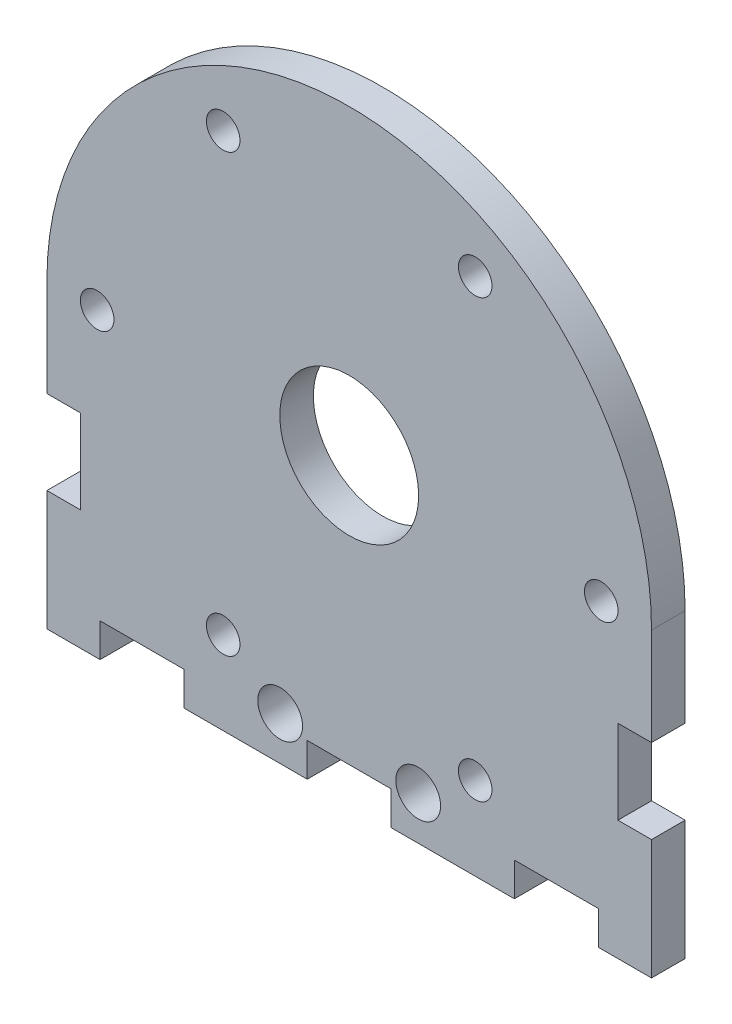
from build123d import *

# Parameters (mm, degrees)
SKETCH_1_R      = 1.5
SKETCH_1_R_2    = 2
SKETCH_1_R_3    = 6.2
EXTRUDE_1_DEPTH = 3


with BuildPart() as part:
    # 草图1 → 凸台-拉伸1 (new body)
    with BuildSketch(Plane.XY):
        with BuildLine():
            Line((2522.174251857, 1992.03397428), (2522.174251857, 1983.327521496))
            Line((2522.174251857, 1983.327521496), (2519.174251857, 1983.327521496))
            Line((2519.174251857, 1983.327521496), (2519.174251857, 1975.827521496))
            Line((2519.174251857, 1975.827521496), (2522.174251857, 1975.827521496))
            Line((2522.174251857, 1975.827521496), (2522.174251857, 1965.121068713))
            Line((2522.174251857, 1965.121068713), (2517.424251857, 1965.121068713))
            Line((2517.424251857, 1965.121068713), (2517.424251857, 1968.121068713))
            Line((2517.424251857, 1968.121068713), (2509.924251857, 1968.121068713))
            Line((2509.924251857, 1968.121068713), (2509.924251857, 1965.121068713))
            Line((2509.924251857, 1965.121068713), (2498.924251857, 1965.121068713))
            Line((2498.924251857, 1965.121068713), (2498.924251857, 1968.121068713))
            Line((2498.924251857, 1968.121068713), (2491.424251857, 1968.121068713))
            Line((2491.424251857, 1968.121068713), (2491.424251857, 1965.121068713))
            Line((2491.424251857, 1965.121068713), (2480.424251857, 1965.121068713))
            Line((2480.424251857, 1965.121068713), (2480.424251857, 1968.121068713))
            Line((2480.424251857, 1968.121068713), (2472.924251857, 1968.121068713))
            Line((2472.924251857, 1968.121068713), (2472.924251857, 1965.121068713))
            Line((2472.924251857, 1965.121068713), (2468.174251857, 1965.121068713))
            Line((2468.174251857, 1965.121068713), (2468.174251857, 1975.827521496))
            Line((2468.174251857, 1975.827521496), (2471.174251857, 1975.827521496))
            Line((2471.174251857, 1975.827521496), (2471.174251857, 1983.327521496))
            Line((2471.174251857, 1983.327521496), (2468.174251857, 1983.327521496))
            Line((2468.174251857, 1983.327521496), (2468.174251857, 1992.03397428))
            ThreePointArc((2468.174251857, 1992.03397428), (2495.174251857, 2019.03397428), (2522.174251857, 1992.03397428))
        make_face()
        with Locations((2472.663889086, 1992.03397428)):
            Circle(SKETCH_1_R, mode=Mode.SUBTRACT)
        with Locations((2483.919070472, 2011.528520288)):
            Circle(SKETCH_1_R, mode=Mode.SUBTRACT)
        with Locations((2506.429433243, 2011.528520288)):
            Circle(SKETCH_1_R, mode=Mode.SUBTRACT)
        with Locations((2517.684614628, 1992.03397428)):
            Circle(SKETCH_1_R, mode=Mode.SUBTRACT)
        with Locations((2501.338054428, 1969.0074786)):
            Circle(SKETCH_1_R_2, mode=Mode.SUBTRACT)
        with Locations((2483.919070472, 1972.539428272)):
            Circle(SKETCH_1_R, mode=Mode.SUBTRACT)
        with Locations((2506.429433243, 1972.539428272)):
            Circle(SKETCH_1_R, mode=Mode.SUBTRACT)
        with Locations((2489.010449286, 1969.0074786)):
            Circle(SKETCH_1_R_2, mode=Mode.SUBTRACT)
        with Locations((2495.174251857, 1992.03397428)):
            Circle(SKETCH_1_R_3, mode=Mode.SUBTRACT)
    extrude(amount=EXTRUDE_1_DEPTH)


solid = part.part
